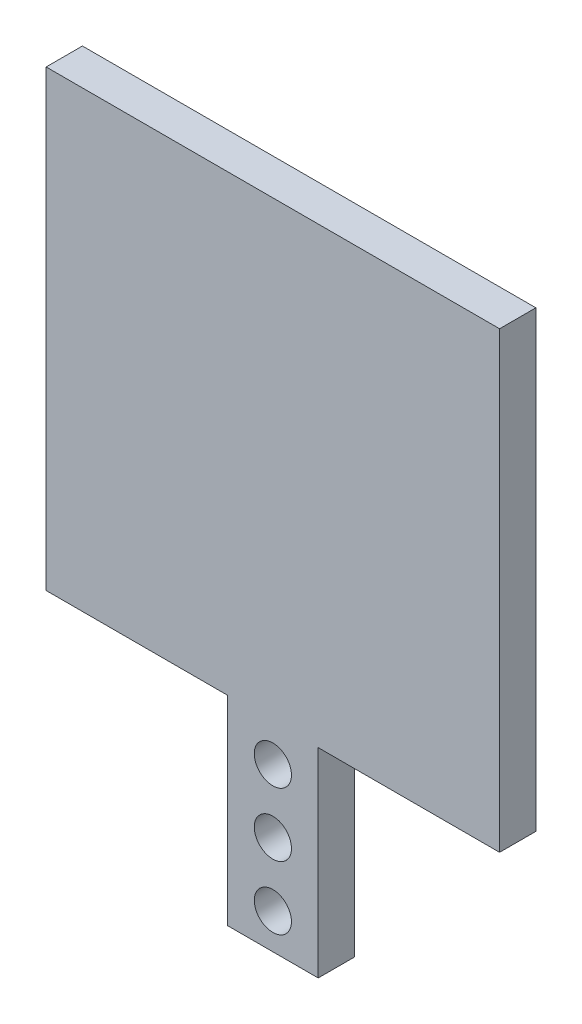
from build123d import *

# Parameters (mm, degrees)
SKETCH1_R           = 2.05
BOSS_EXTRUDE1_DEPTH = 4


with BuildPart() as part:
    # Sketch1 → Boss-Extrude1 (new body)
    with BuildSketch(Plane.XY):
        Polygon((0, 0), (20, 0), (20, -22), (30, -22), (30, 0), (50, 0), (50, 50), (0, 50), align=None)
        with Locations((25, -18.1)):
            Circle(SKETCH1_R, mode=Mode.SUBTRACT)
        with Locations((25, -11.1)):
            Circle(SKETCH1_R, mode=Mode.SUBTRACT)
        with Locations((25, -4.1)):
            Circle(SKETCH1_R, mode=Mode.SUBTRACT)
    extrude(amount=BOSS_EXTRUDE1_DEPTH)


solid = part.part
